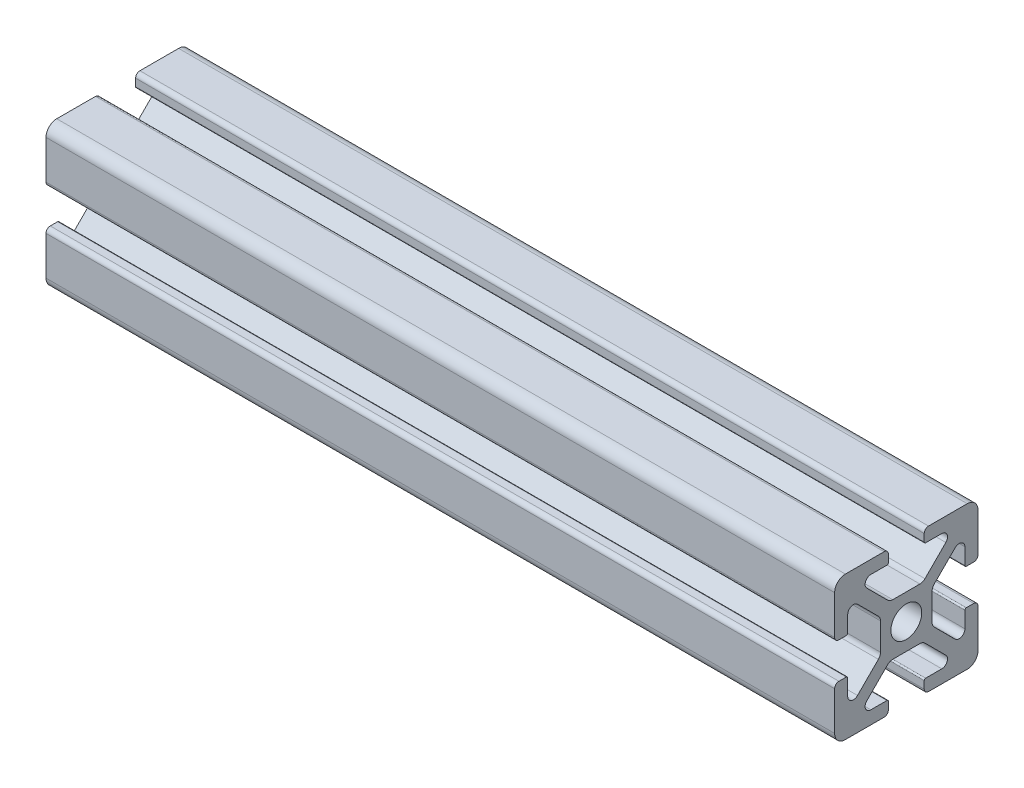
from build123d import *

# Parameters (mm, degrees)
BOSS_EXTRUDE1_DEPTH = 110


with BuildPart() as part:
    # Sketch3 → Boss-Extrude1 (new body)
    with BuildSketch(Plane(origin=(0, 0, 0), x_dir=(0, 0, -1), z_dir=(1, 0, 0))):
        with BuildLine():
            Line((-5.515685425, 6.807463915), (-2.601114729, 3.892893219))
            ThreePointArc((-2.601114729, 3.892893219), (-2.27669138, 3.676120467), (-1.894007948, 3.6))
            Line((-1.894007948, 3.6), (0, 3.6))
            Line((0, 3.6), (0, 2.15))
            ThreePointArc((0, 2.15), (-1.52027958, 1.52027958), (-2.15, 0))
            Line((-2.15, 0), (-3.6, 0))
            Line((-3.6, 0), (-3.6, 1.894007948))
            ThreePointArc((-3.6, 1.894007948), (-3.676120467, 2.27669138), (-3.892893219, 2.601114729))
            Line((-3.892893219, 2.601114729), (-6.807463915, 5.515685425))
            ThreePointArc((-6.807463915, 5.515685425), (-7.679296086, 5.689103626), (-8.17314934, 4.95))
            Line((-8.17314934, 4.95), (-8.17314934, 2.7))
            ThreePointArc((-8.17314934, 2.7), (-8.231727984, 2.558578644), (-8.37314934, 2.5))
            Line((-8.37314934, 2.5), (-9.4, 2.5))
            ThreePointArc((-9.4, 2.5), (-9.824264069, 2.675735931), (-10, 3.1))
            Line((-10, 3.1), (-10, 8.5))
            ThreePointArc((-10, 8.5), (-9.560660172, 9.560660172), (-8.5, 10))
            Line((-8.5, 10), (-3.1, 10))
            ThreePointArc((-3.1, 10), (-2.675735931, 9.824264069), (-2.5, 9.4))
            Line((-2.5, 9.4), (-2.5, 8.37314934))
            ThreePointArc((-2.5, 8.37314934), (-2.558578644, 8.231727984), (-2.7, 8.17314934))
            Line((-2.7, 8.17314934), (-4.95, 8.17314934))
            ThreePointArc((-4.95, 8.17314934), (-5.689103626, 7.679296086), (-5.515685425, 6.807463915))
        make_face()
    extrude(amount=-BOSS_EXTRUDE1_DEPTH)

    # Mirror1: part across plane


with BuildPart() as part_1:
    add(part.part)
    add(part.part.mirror(Plane.ZX))

    # Mirror2: part across plane


with BuildPart() as part_2:
    add(part_1.part)
    add(part_1.part.mirror(Plane.XY))


solid = part_2.part
